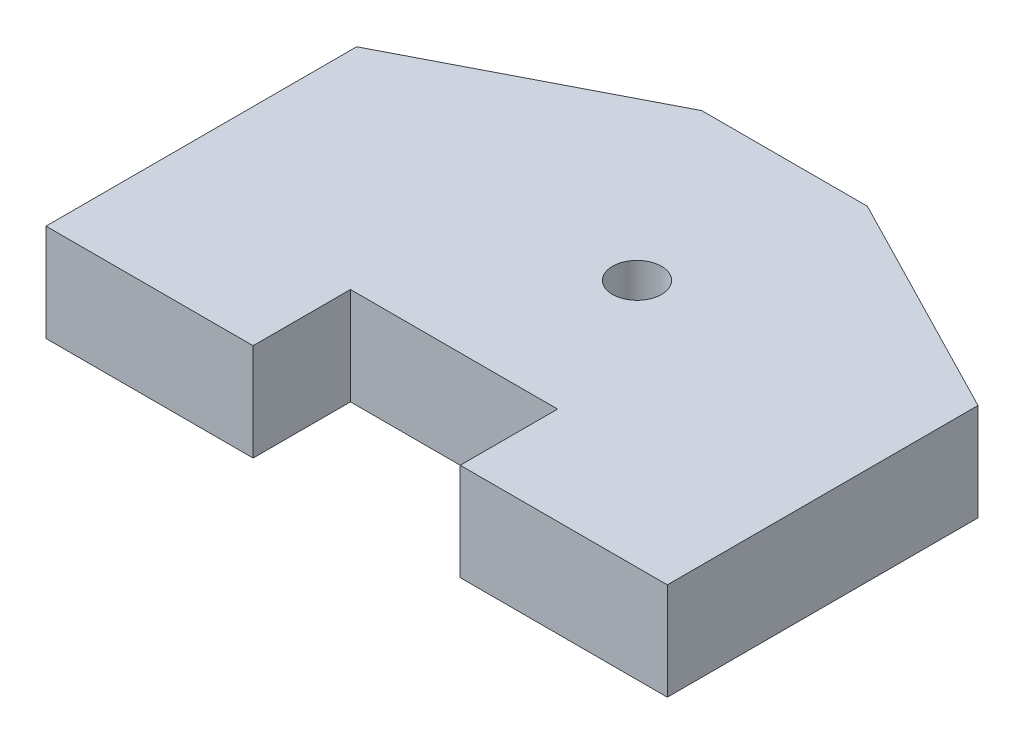
from build123d import *

# Parameters (mm, degrees)
SKETCH1_R           = 1.5
BOSS_EXTRUDE1_DEPTH = 5.969


with BuildPart() as part:
    # Sketch1 → Boss-Extrude1 (new body)
    with BuildSketch(Plane(origin=(0, 0, 0), x_dir=(1, 0, 0), z_dir=(0, 1, 0))):
        Polygon((0, 19.05), (13.97, 26.238715005), (24.13, 26.238715005), (38.1, 19.05), (38.1, 0), (25.4, 0), (25.4, 5.969), (12.7, 5.969), (12.7, 0), (0, 0), align=None)
        with Locations((21, 15.24)):
            Circle(SKETCH1_R, mode=Mode.SUBTRACT)
    extrude(amount=BOSS_EXTRUDE1_DEPTH)


solid = part.part
